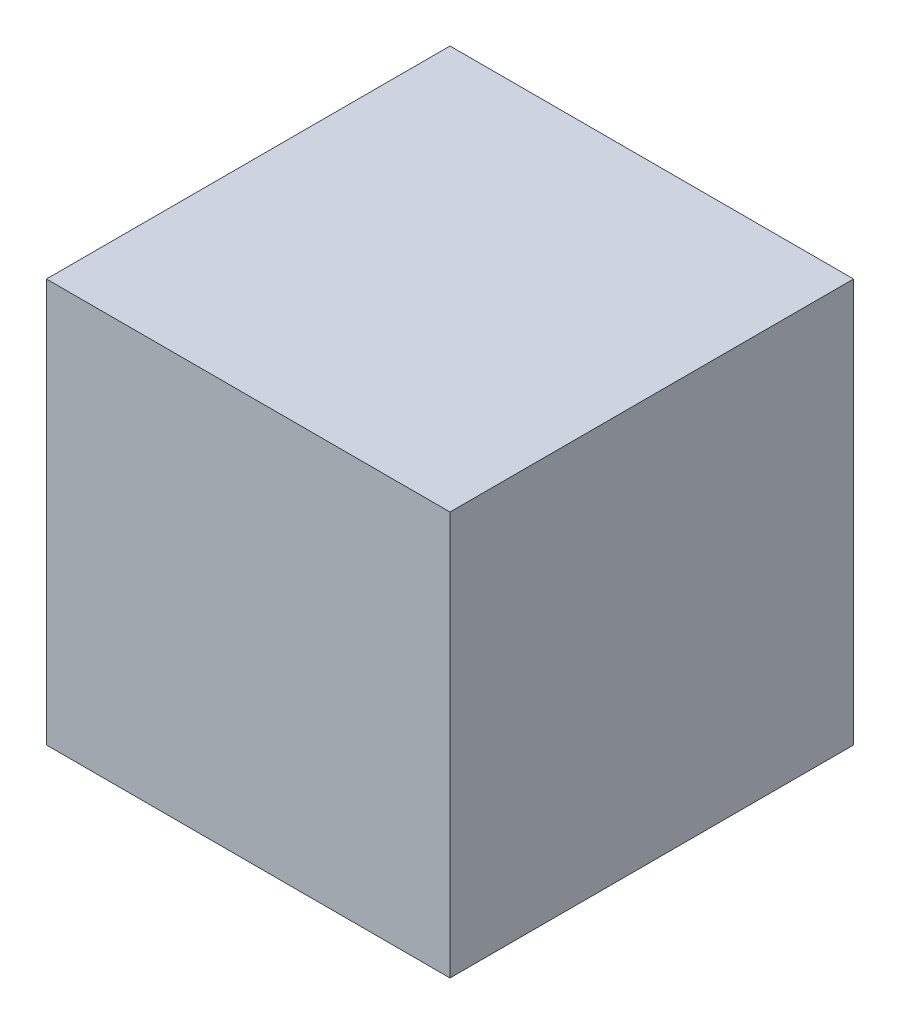
from build123d import *

# Parameters (mm, degrees)
SKETCH1_W           = 70.7
SKETCH1_H           = 70.7
BOSS_EXTRUDE1_DEPTH = 70.7


with BuildPart() as part:
    # Sketch1 → Boss-Extrude1 (new body)
    with BuildSketch(Plane(origin=(0, 0, 0), x_dir=(1, 0, 0), z_dir=(0, 1, 0))):
        Rectangle(SKETCH1_W, SKETCH1_H)
    extrude(amount=-BOSS_EXTRUDE1_DEPTH)


solid = part.part
